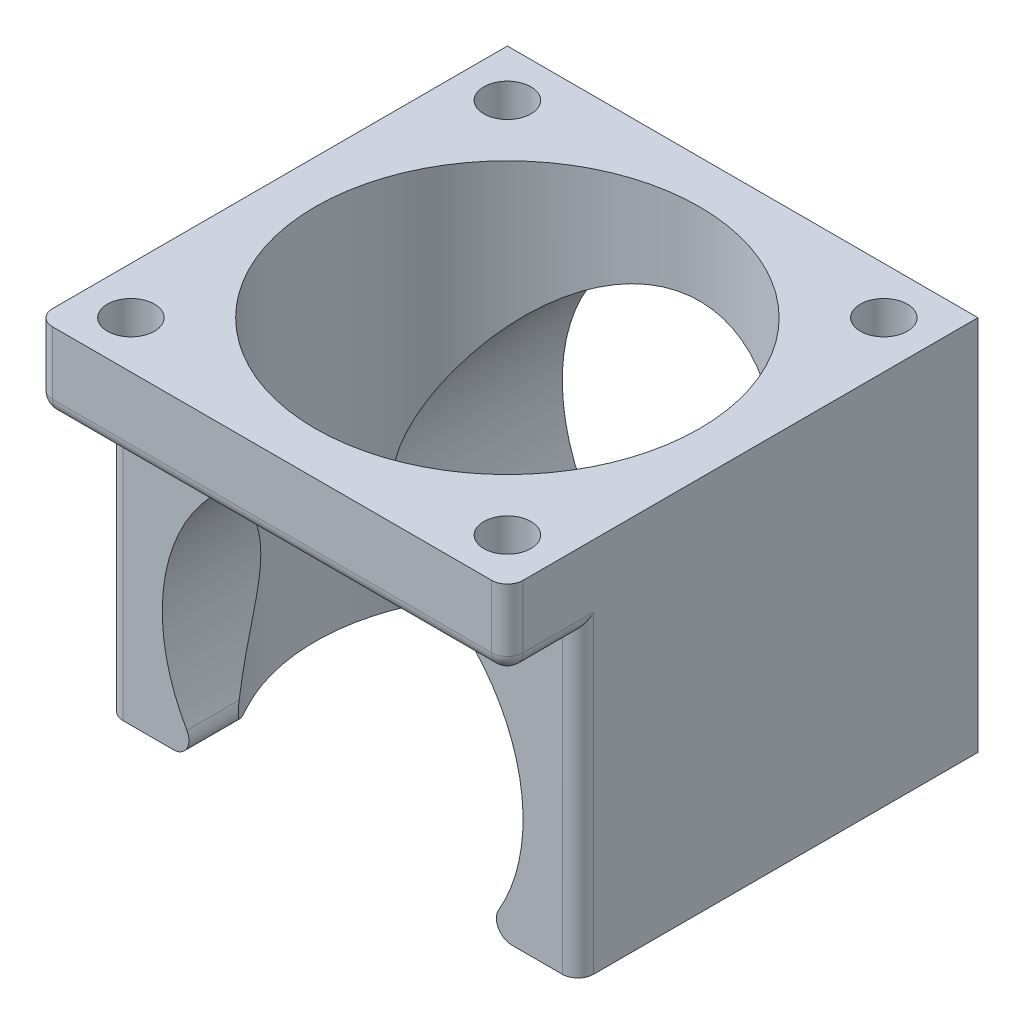
from build123d import *

# Parameters (mm, degrees)
SKETCH1_R           = 1.5
BOSS_EXTRUDE1_DEPTH = 5
SKETCH3_W           = 30
SKETCH3_H           = 25.5
BOSS_EXTRUDE2_DEPTH = 19
CUT_EXTRUDE7_DEPTH  = 26.5
FILLET10_R          = 1
FILLET11_R          = 1
CUT_EXTRUDE9_DEPTH  = 20


with BuildPart() as part:
    # Sketch1 → Boss-Extrude1 (new body)
    with BuildSketch(Plane(origin=(0, 0, 0), x_dir=(1, 0, 0), z_dir=(0, 1, 0))):
        with BuildLine():
            Line((-15.898648649, -5.337837838), (-18.648648649, -5.337837838))
            Line((-18.648648649, -5.337837838), (-18.648648649, -20.337837838))
            Line((-18.648648649, -20.337837838), (-3.648648649, -20.337837838))
            Line((-3.648648649, -20.337837838), (-3.648648649, -17.587837838))
            ThreePointArc((-3.648648649, -17.587837838), (-12.310706718, -13.999895907), (-15.898648649, -5.337837838))
        make_face()
        with Locations((-15.648648649, -17.337837838)):
            Circle(SKETCH1_R, mode=Mode.SUBTRACT)
        with BuildLine():
            ThreePointArc((8.601351351, -5.337837838), (5.013409421, -13.999895907), (-3.648648649, -17.587837838))
            Line((-3.648648649, -17.587837838), (-3.648648649, -20.337837838))
            Line((-3.648648649, -20.337837838), (11.351351351, -20.337837838))
            Line((11.351351351, -20.337837838), (11.351351351, -5.337837838))
            Line((11.351351351, -5.337837838), (8.601351351, -5.337837838))
        make_face()
        with Locations((8.351351351, -17.337837838)):
            Circle(SKETCH1_R, mode=Mode.SUBTRACT)
        with BuildLine():
            Line((-3.648648649, 9.662162162), (-3.648648649, 6.912162162))
            ThreePointArc((-3.648648649, 6.912162162), (5.013409421, 3.324220232), (8.601351351, -5.337837838))
            Line((8.601351351, -5.337837838), (11.351351351, -5.337837838))
            Line((11.351351351, -5.337837838), (11.351351351, 9.662162162))
            Line((11.351351351, 9.662162162), (-3.648648649, 9.662162162))
        make_face()
        with Locations((8.351351351, 6.662162162)):
            Circle(SKETCH1_R, mode=Mode.SUBTRACT)
        with BuildLine():
            Line((-18.648648649, 9.662162162), (-18.648648649, -5.337837838))
            Line((-18.648648649, -5.337837838), (-15.898648649, -5.337837838))
            ThreePointArc((-15.898648649, -5.337837838), (-12.310706718, 3.324220232), (-3.648648649, 6.912162162))
            Line((-3.648648649, 6.912162162), (-3.648648649, 9.662162162))
            Line((-3.648648649, 9.662162162), (-18.648648649, 9.662162162))
        make_face()
        with Locations((-15.648648649, 6.662162162)):
            Circle(SKETCH1_R, mode=Mode.SUBTRACT)
    extrude(amount=BOSS_EXTRUDE1_DEPTH)

    # Sketch3 → Boss-Extrude2 (add)
    with BuildSketch(Plane.XZ):
        with Locations((-3.648648649, 3.087837838)):
            Rectangle(SKETCH3_W, SKETCH3_H)
    extrude(amount=BOSS_EXTRUDE2_DEPTH)

    # Sketch4 → Cut-Extrude7 (cut, through all)
    with BuildSketch(Plane.XY.offset(15.837837838)):
        with BuildLine():
            ThreePointArc((7.851351351, -11.7), (4.483079335, -3.568272016), (-3.648648649, -0.2))
            Line((-3.648648649, -0.2), (-3.648648649, -19))
            Line((-3.648648649, -19), (5.237295308, -19))
            ThreePointArc((5.237295308, -19), (7.178131932, -15.57696044), (7.851351351, -11.7))
        make_face()
        with BuildLine():
            Line((-3.648648649, -19), (-3.648648649, -0.2))
            ThreePointArc((-3.648648649, -0.2), (-14.045763633, -6.78573505), (-12.534592605, -19))
            Line((-12.534592605, -19), (-3.648648649, -19))
        make_face()
        with BuildLine():
            Line((5.237295308, -19), (-3.648648649, -19))
            Line((-3.648648649, -19), (-3.648648649, -23.2))
            ThreePointArc((-3.648648649, -23.2), (1.265616301, -22.097114984), (5.237295308, -19))
        make_face()
        with BuildLine():
            Line((-3.648648649, -23.2), (-3.648648649, -19))
            Line((-3.648648649, -19), (-12.534592605, -19))
            ThreePointArc((-12.534592605, -19), (-8.562913599, -22.097114984), (-3.648648649, -23.2))
        make_face()
    extrude(amount=-CUT_EXTRUDE7_DEPTH, mode=Mode.SUBTRACT)

    # Fillet10
    fillet10_edges = [part.edges().sort_by_distance(p)[0] for p in [
        (11.351351351, 2.5, 20.337837838),
        (-18.648648649, 2.5, 20.337837838),
        (-18.648648649, 0, 18.087837838),
        (-18.648648649, -9.5, 15.837837838),
        (11.351351351, -9.5, 15.837837838),
        (11.351351351, 0, 18.087837838),
        (-3.648648649, 0, 20.337837838),
    ]]
    fillet(fillet10_edges, radius=FILLET10_R)

    # Fillet11
    fillet11_edges = [part.edges().sort_by_distance(p)[0] for p in [
        (5.237295308, -19, 3.087837838),
        (-12.534592605, -19, 3.087837838),
    ]]
    fillet(fillet11_edges, radius=FILLET11_R)

    # Sketch5 → Cut-Extrude9 (cut, through all)
    with BuildSketch(Plane(origin=(0, 0, 0), x_dir=(1, 0, 0), z_dir=(0, 1, 0))):
        with BuildLine():
            ThreePointArc((2.661066083, -15.837837838), (-3.648648649, 6.912162162), (-9.958363381, -15.837837838))
            Line((-9.958363381, -15.837837838), (2.661066083, -15.837837838))
        make_face()
    extrude(amount=-CUT_EXTRUDE9_DEPTH, mode=Mode.SUBTRACT)


solid = part.part
